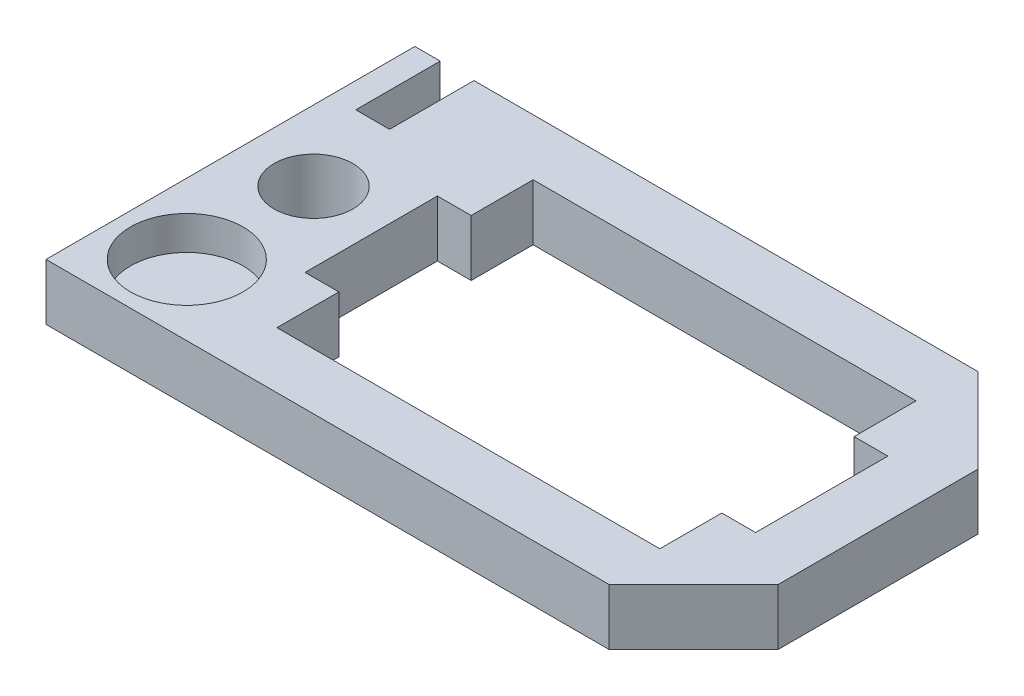
from build123d import *

# Parameters (mm, degrees)
ESQUISSE1_W             = 23
ESQUISSE1_H             = 13.1
BOSS_EXTRU_1_DEPTH      = 2
ENL_V_MAT_EXTRU_4_REACH = 4
ESQUISSE2_R             = 1.4
CHANFREIN1_SIZE         = 3
ESQUISSE3_W             = 1.2
ESQUISSE3_H             = 2
ENL_V_MAT_EXTRU_5_DEPTH = 3
ESQUISSE4_R             = 2
ENL_V_MAT_EXTRU_6_DEPTH = 1.2


with BuildPart() as part:
    # Esquisse1 → Boss.-Extru.1 (new body)
    with BuildSketch(Plane(origin=(0, 0, 0), x_dir=(1, 0, 0), z_dir=(0, 1, 0))):
        with Locations((11.5, 6.55)):
            Rectangle(ESQUISSE1_W, ESQUISSE1_H)
        Polygon((6.2, 8.9), (6.2, 11.1), (19.8, 11.1), (19.8, 8.9), (21, 8.9), (21, 4.2), (19.8, 4.2), (19.8, 2), (6.2, 2), (6.2, 4.2), (5, 4.2), (5, 8.9), align=None, mode=Mode.SUBTRACT)
    extrude(amount=BOSS_EXTRU_1_DEPTH)

    # Esquisse2 → Enlèv. mat.-Extru.4 (cut, up to next)
    with BuildSketch(Plane(origin=(0, 2, 0), x_dir=(1, 0, 0), z_dir=(0, 1, 0)), mode=Mode.PRIVATE) as enl_v_mat_extru_4_sk1:
        with Locations((2.5, 7)):
            Circle(ESQUISSE2_R)
    enl_v_mat_extru_4_tool1 = extrude(enl_v_mat_extru_4_sk1.sketch, amount=-ENL_V_MAT_EXTRU_4_REACH, mode=Mode.PRIVATE) & part.part
    add(enl_v_mat_extru_4_tool1.solids().sort_by_distance((2.5, 2, -7))[0], mode=Mode.SUBTRACT)

    # Chanfrein1
    chanfrein1_edges = [part.edges().sort_by_distance(p)[0] for p in [
        (23, 1, -13.1),
        (23, 1, 0),
    ]]
    chamfer(chanfrein1_edges, length=CHANFREIN1_SIZE)

    # Esquisse3 → Enlèv. mat.-Extru.5 (cut)
    with BuildSketch(Plane(origin=(0, 0, -13.1), x_dir=(-1, 0, 0), z_dir=(0, 0, -1))):
        with Locations((-1.5, 1)):
            Rectangle(ESQUISSE3_W, ESQUISSE3_H)
    extrude(amount=-ENL_V_MAT_EXTRU_5_DEPTH, mode=Mode.SUBTRACT)

    # Esquisse4 → Enlèv. mat.-Extru.6 (cut)
    with BuildSketch(Plane(origin=(0, 2, 0), x_dir=(1, 0, 0), z_dir=(0, 1, 0))):
        with Locations((2.5, 2.5)):
            Circle(ESQUISSE4_R)
    extrude(amount=-ENL_V_MAT_EXTRU_6_DEPTH, mode=Mode.SUBTRACT)


solid = part.part
